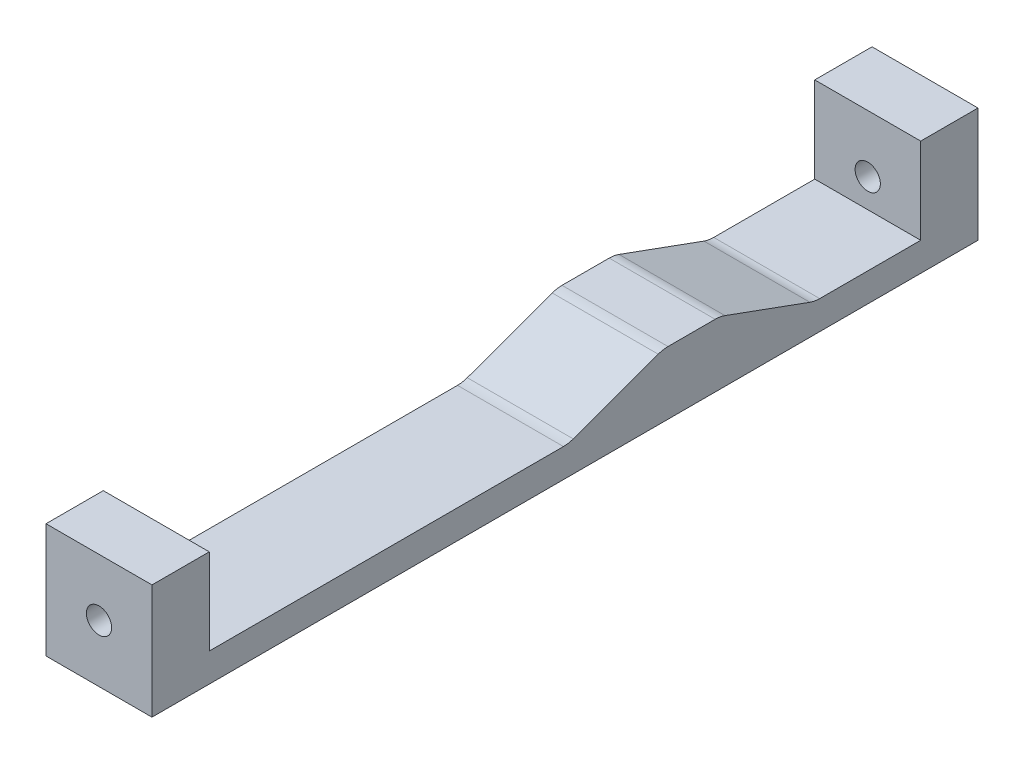
from build123d import *

# Parameters (mm, degrees)
SKETCH1_W           = 11.7475
SKETCH1_H           = 91.567
BOSS_EXTRUDE1_DEPTH = 3.175
SKETCH5_W           = 11.7475
SKETCH5_H           = 9.525
BOSS_EXTRUDE2_DEPTH = 6.35
SKETCH4_R           = 1.399999994
CUT_EXTRUDE1_DEPTH  = 92.567
BOSS_EXTRUDE3_DEPTH = 11.7475
FILLET1_R           = 3.175


with BuildPart() as part:
    # Sketch1 → Boss-Extrude1 (new body)
    with BuildSketch(Plane(origin=(0, 0, 0), x_dir=(1, 0, 0), z_dir=(0, 1, 0))):
        Rectangle(SKETCH1_W, SKETCH1_H)
    extrude(amount=BOSS_EXTRUDE1_DEPTH)

    # Sketch5 → Boss-Extrude2 (add)
    with BuildSketch(Plane.XY.offset(45.7835)):
        with Locations((0, 7.9375)):
            Rectangle(SKETCH5_W, SKETCH5_H)
    boss_extrude2 = extrude(amount=-BOSS_EXTRUDE2_DEPTH)

    # Mirror1: Boss-Extrude2 across plane
    add(boss_extrude2.mirror(Plane.XY))

    # Sketch4 → Cut-Extrude1 (cut, through all)
    with BuildSketch(Plane.XY.offset(45.7835)):
        with Locations((0, 6.35)):
            Circle(SKETCH4_R)
    extrude(amount=-CUT_EXTRUDE1_DEPTH, mode=Mode.SUBTRACT)

    # Sketch6 → Boss-Extrude3 (add)
    with BuildSketch(Plane.ZY.offset(5.87375)):
        Polygon((-17.2085, 6.985), (-10.8585, 6.985), (-0.390611032, 3.175), (-27.676388968, 3.175), align=None)
    extrude(amount=-BOSS_EXTRUDE3_DEPTH)

    # Fillet1
    fillet1_edges = [part.edges().sort_by_distance(p)[0] for p in [
        (0, 3.175, -27.676388968),
        (0, 6.985, -17.2085),
        (0, 6.985, -10.8585),
        (0, 3.175, -0.390611032),
    ]]
    fillet(fillet1_edges, radius=FILLET1_R)


solid = part.part
